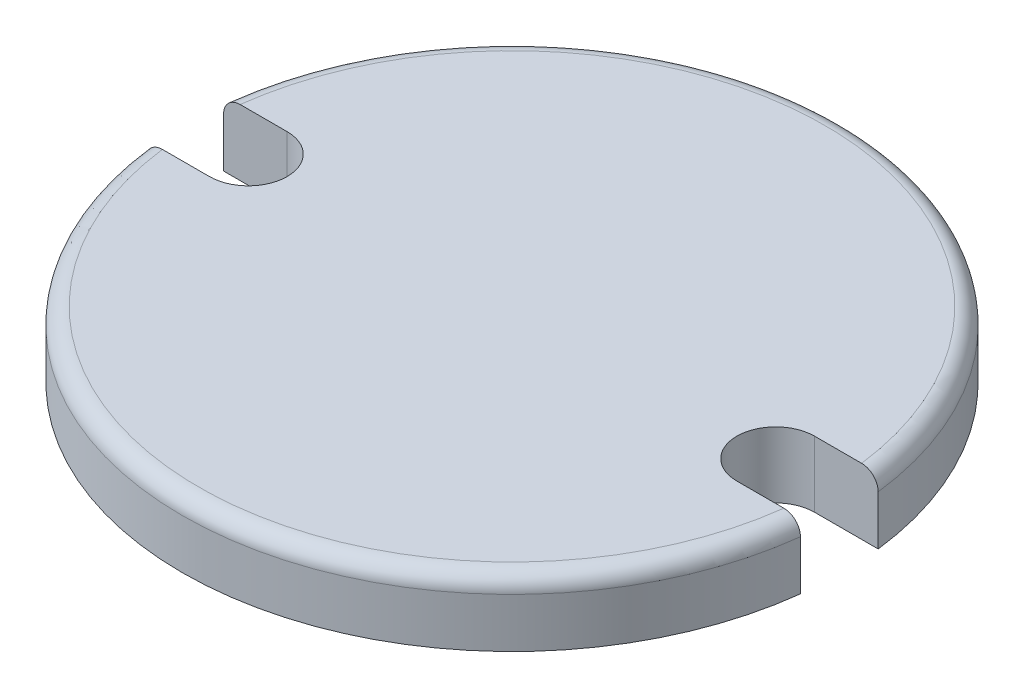
from build123d import *

# Parameters (mm, degrees)
SKETCH1_R           = 63.5
BOSS_EXTRUDE2_DEPTH = 12.7
FILLET2_R           = 3.17
CUT_EXTRUDE1_DEPTH  = 13.7


with BuildPart() as part:
    # Sketch1 → Boss-Extrude2 (new body)
    with BuildSketch(Plane(origin=(0, 0, 0), x_dir=(1, 0, 0), z_dir=(0, 1, 0))):
        Circle(SKETCH1_R)
    extrude(amount=BOSS_EXTRUDE2_DEPTH)

    # Fillet2
    fillet2_edges = [part.edges().sort_by_distance(p)[0] for p in [
        (-63.5, 12.7, 0),
    ]]
    fillet(fillet2_edges, radius=FILLET2_R)

    # Sketch3 → Cut-Extrude1 (cut, through all)
    with BuildSketch(Plane(origin=(0, 12.7, 0), x_dir=(1, 0, 0), z_dir=(0, 1, 0))):
        with BuildLine():
            Line((-50.8, 7.49), (-63.056719705, 7.49))
            ThreePointArc((-63.056719705, 7.49), (-63.5, 0), (-63.056719705, -7.49))
            Line((-63.056719705, -7.49), (-50.8, -7.49))
            ThreePointArc((-50.8, -7.49), (-43.31, 0), (-50.8, 7.49))
        make_face()
        with BuildLine():
            Line((50.8, -7.49), (63.056719705, -7.49))
            ThreePointArc((63.056719705, -7.49), (63.5, 0), (63.056719705, 7.49))
            Line((63.056719705, 7.49), (50.8, 7.49))
            ThreePointArc((50.8, 7.49), (43.31, 0), (50.8, -7.49))
        make_face()
    extrude(amount=-CUT_EXTRUDE1_DEPTH, mode=Mode.SUBTRACT)


solid = part.part
